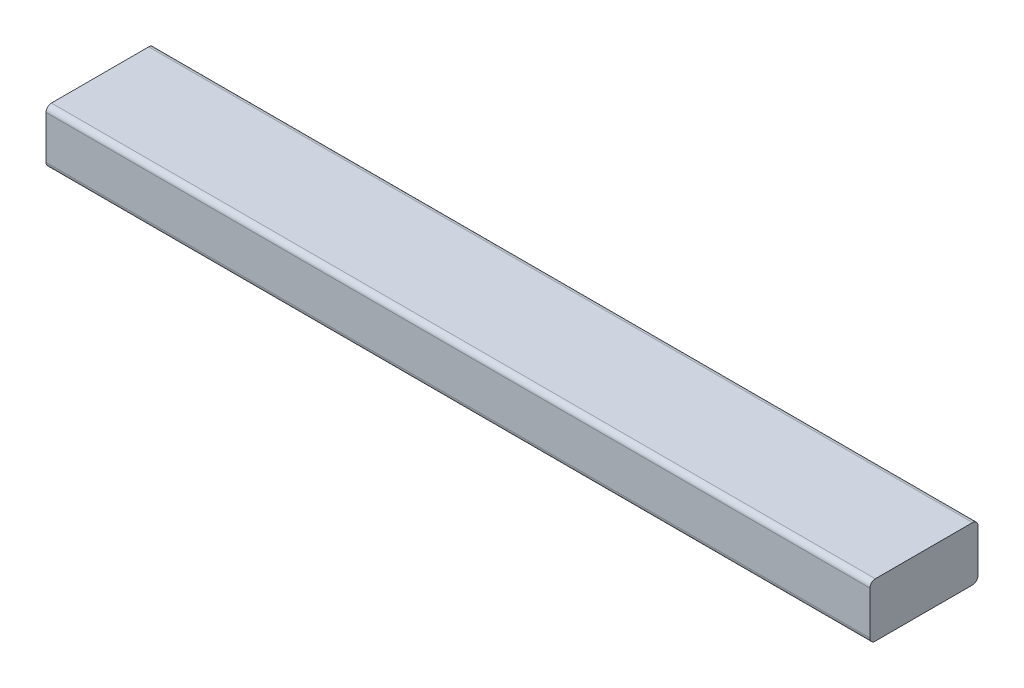
from build123d import *

# Parameters (mm, degrees)
SKETCH1_W           = 774.6
SKETCH1_H           = 101.6
BOSS_EXTRUDE1_DEPTH = 50.8
FILLET1_R           = 5.08


with BuildPart() as part:
    # Sketch1 → Boss-Extrude1 (new body)
    with BuildSketch(Plane(origin=(0, -12.7, 0), x_dir=(-1, 0, 0), z_dir=(0, -1, 0))):
        with Locations((-2200, 211.5)):
            Rectangle(SKETCH1_W, SKETCH1_H)
    extrude(amount=-BOSS_EXTRUDE1_DEPTH)

    # Fillet1
    fillet1_edges = [part.edges().sort_by_distance(p)[0] for p in [
        (2200, 38.1, -262.3),
        (2200, -12.7, -262.3),
        (2200, -12.7, -160.7),
        (2200, 38.1, -160.7),
    ]]
    fillet(fillet1_edges, radius=FILLET1_R)


solid = part.part
